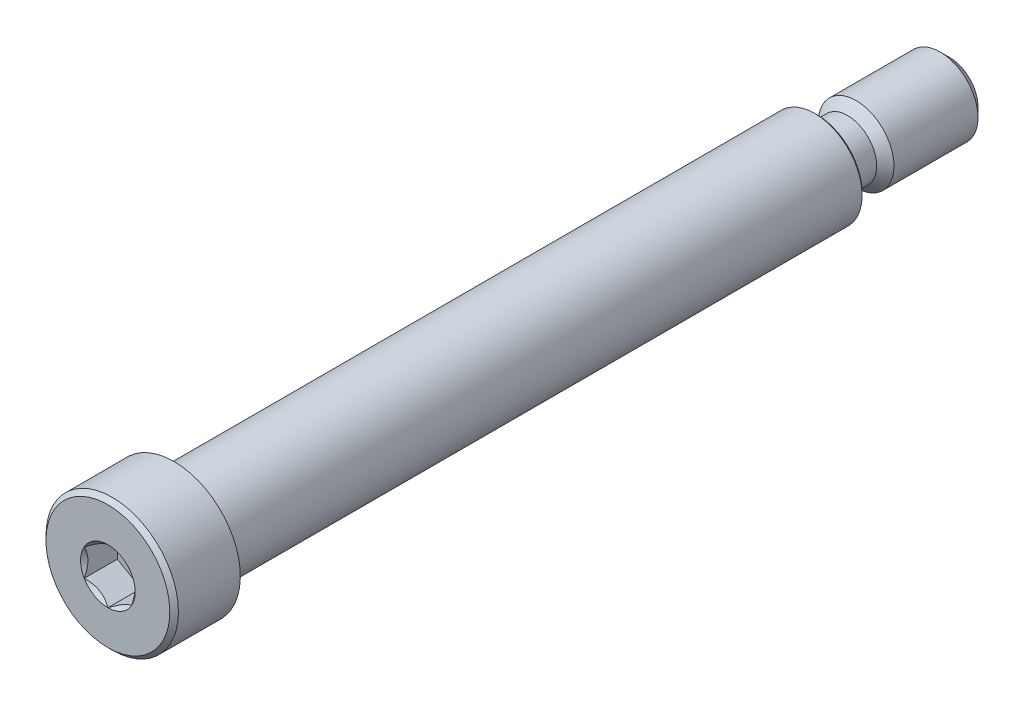
from build123d import *

# Parameters (mm, degrees)
CHAMFER1_SIZE      = 0.79375
CHAMFER2_SIZE      = 0.36115625
CHAMFER3_SIZE      = 0.2032
CUT_EXTRUDE2_DEPTH = 2.778125


with BuildPart() as part:
    # Sketch1 → Revolve1 (revolve)
    with BuildSketch(Plane(origin=(0, 0, 0), x_dir=(0, 0, -1), z_dir=(1, 0, 0))):
        Polygon((0, 5.55625), (5.55625, 5.55625), (5.55625, 3.96875), (59.53125, 3.96875), (59.53125, 3.175), (70.64375, 3.175), (70.64375, 0), (0, 0), align=None)
    revolve(axis=Axis((0, 0, -70.64375), (0, 0, 1)))

    # Sketch5 → Cut-Revolve1 (revolve, cut)
    with BuildSketch(Plane(origin=(0, 0, 0), x_dir=(0, 0, -1), z_dir=(1, 0, 0))):
        with BuildLine():
            Line((59.53125, 3.96875), (63.5889, 3.96875))
            Line((63.5889, 3.96875), (62.07125, 2.4511))
            Line((62.07125, 2.4511), (60.25515, 2.4511))
            ThreePointArc((60.25515, 2.4511), (59.743275401, 2.663125401), (59.53125, 3.175))
            Line((59.53125, 3.175), (59.53125, 3.96875))
        make_face()
    revolve(axis=Axis((0, 0, -70.64375), (0, 0, 1)), mode=Mode.SUBTRACT)

    # Chamfer1
    chamfer1_edges = [part.edges().sort_by_distance(p)[0] for p in [
        (0, -3.175, -70.64375),
    ]]
    chamfer(chamfer1_edges, length=CHAMFER1_SIZE)

    # Chamfer2
    chamfer2_edges = [part.edges().sort_by_distance(p)[0] for p in [
        (0, -5.55625, 0),
    ]]
    chamfer(chamfer2_edges, length=CHAMFER2_SIZE)

    # Chamfer3
    chamfer3_edges = [part.edges().sort_by_distance(p)[0] for p in [
        (0, -3.96875, -59.53125),
    ]]
    chamfer(chamfer3_edges, length=CHAMFER3_SIZE)

    # Sketch8 → Cut-Extrude2 (cut)
    with BuildSketch(Plane.XY):
        Polygon((1.984375, 1.14567944), (0, 2.291358881), (-1.984375, 1.14567944), (-1.984375, -1.14567944), (0, -2.291358881), (1.984375, -1.14567944), align=None)
    extrude(amount=-CUT_EXTRUDE2_DEPTH, mode=Mode.SUBTRACT)

    # Cut-Extrude4 cone 1 section (through the dimple's axis) → Cut-Extrude4 (revolve, cut)
    with BuildSketch(Plane(origin=(0, 0, 0), x_dir=(0, -1, 0), z_dir=(1, 0, 0))):
        Polygon((0, 0), (2.291358881, 0), (0, 2.291358881), align=None)
    revolve(axis=Axis((0, 0, 0), (0, 0, -1)), mode=Mode.SUBTRACT)


solid = part.part
